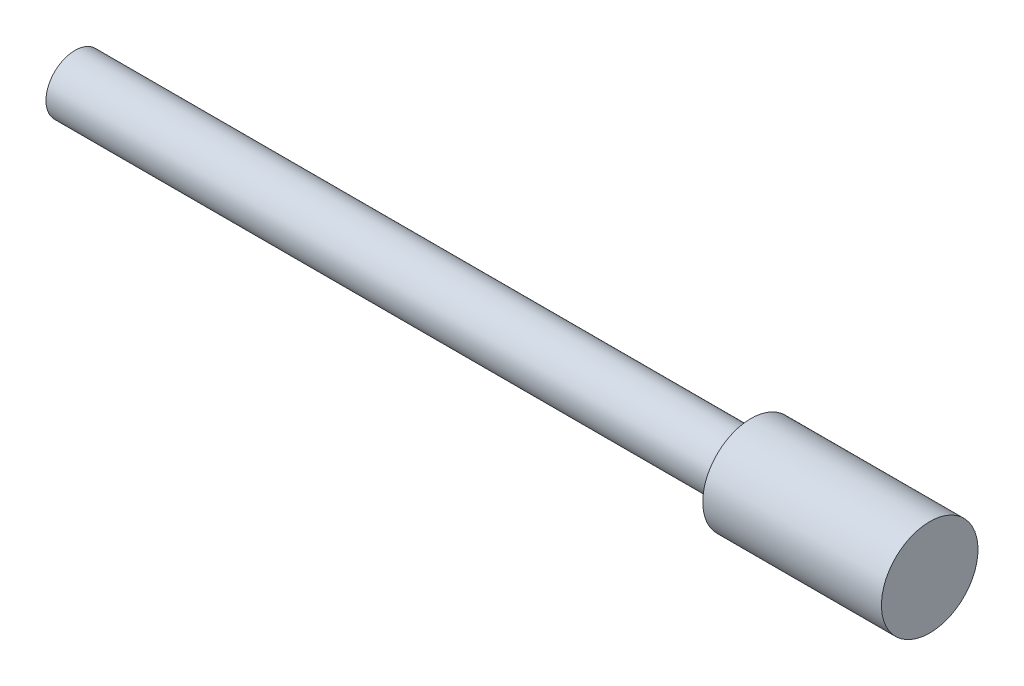
from build123d import *

# Parameters (mm, degrees)
SKETCH1_R           = 6
BOSS_EXTRUDE1_DEPTH = 140
SKETCH2_R           = 10
BOSS_EXTRUDE2_DEPTH = 37


with BuildPart() as part:
    # Sketch1 → Boss-Extrude1 (new body)
    with BuildSketch(Plane(origin=(0, 0, 0), x_dir=(0, 0, -1), z_dir=(1, 0, 0))):
        Circle(SKETCH1_R)
    extrude(amount=BOSS_EXTRUDE1_DEPTH)

    # Sketch2 → Boss-Extrude2 (add)
    with BuildSketch(Plane(origin=(140, 0, 0), x_dir=(0, 0, -1), z_dir=(1, 0, 0))):
        Circle(SKETCH2_R)
    extrude(amount=BOSS_EXTRUDE2_DEPTH)


solid = part.part
